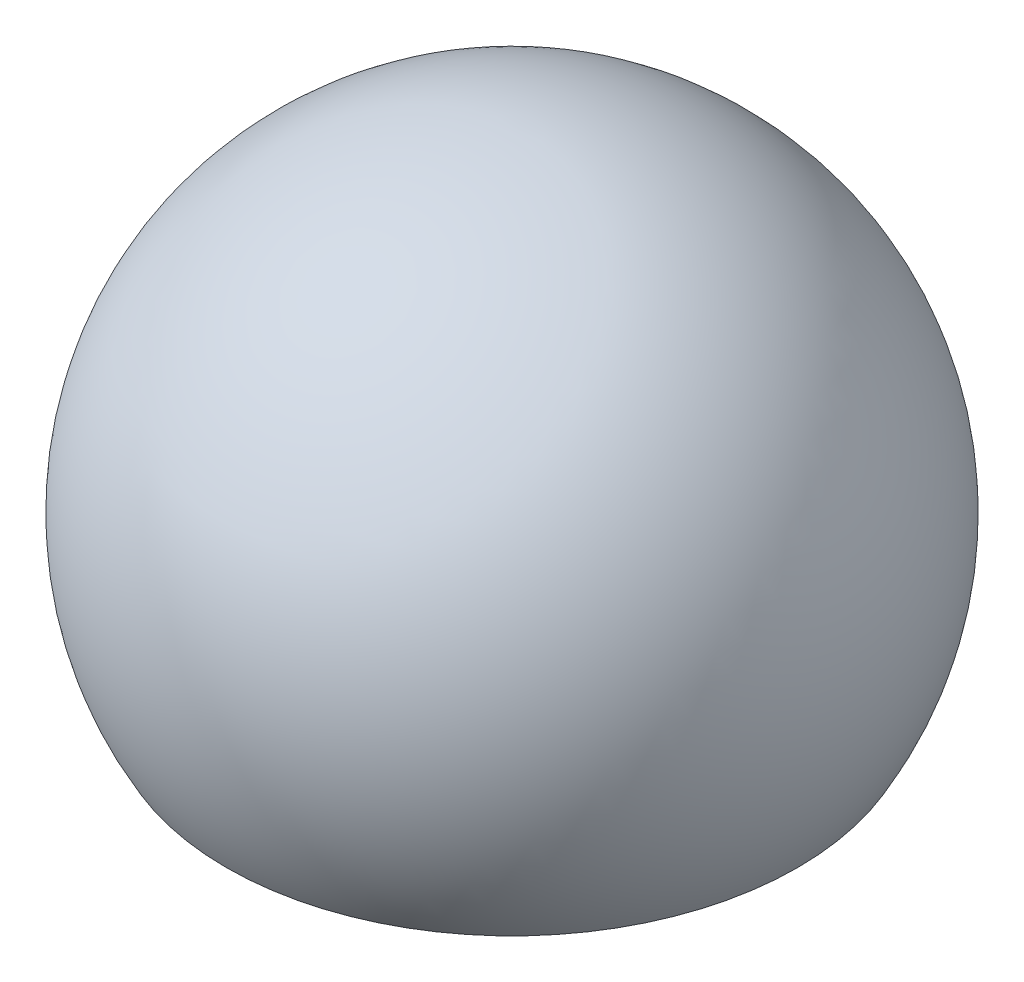
from build123d import *

# Parameters (mm, degrees)
TRUNCATED_BALL_DEPTH      = 13.7
TRUNCATED_BALL_DEPTH_BACK = 13.7


with BuildPart() as part:
    # Sketch1 → Complete_Ball (revolve)
    with BuildSketch(Plane.XY):
        with BuildLine():
            Line((0, 12.7), (0, -12.7))
            ThreePointArc((0, -12.7), (12.7, 0), (0, 12.7))
        make_face()
    revolve(axis=Axis((0, 13.6525, 0), (0, -1, 0)))

    # Sketch2 → Truncated_ball (cut, two sides)
    with BuildSketch(Plane.XY) as truncated_ball_sk:
        with BuildLine():
            Line((-10.998522628, -6.35), (10.998522628, -6.35))
            ThreePointArc((10.998522628, -6.35), (0, -12.7), (-10.998522628, -6.35))
        make_face()
    extrude(amount=TRUNCATED_BALL_DEPTH, mode=Mode.SUBTRACT)
    extrude(truncated_ball_sk.sketch, amount=-TRUNCATED_BALL_DEPTH_BACK, mode=Mode.SUBTRACT)


solid = part.part
